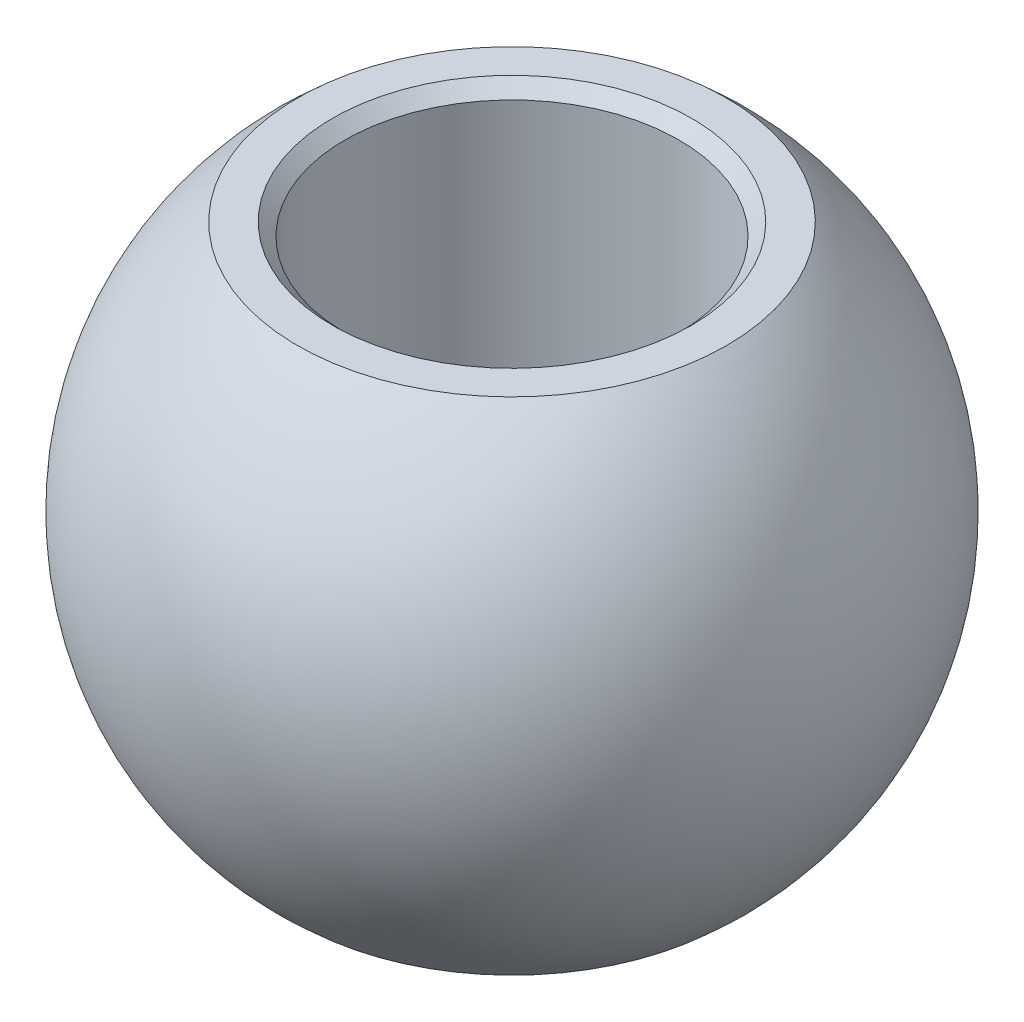
from build123d import *

# Parameters (mm, degrees)
CHAMFER1_SIZE = 0.3


with BuildPart() as part:
    # Sketch1 → Revolve1 (revolve)
    with BuildSketch(Plane.XY):
        with BuildLine():
            Line((-4, -6), (-4, 6))
            Line((-4, 6), (-5.139066063, 6))
            ThreePointArc((-5.139066063, 6), (-7.9, 0), (-5.139066063, -6))
            Line((-5.139066063, -6), (-4, -6))
        make_face()
    revolve(axis=Axis((0, -6, 0), (0, 1, 0)))

    # Chamfer1
    chamfer1_edges = [part.edges().sort_by_distance(p)[0] for p in [
        (4, 6, 0),
        (4, -6, 0),
    ]]
    chamfer(chamfer1_edges, length=CHAMFER1_SIZE)


solid = part.part
